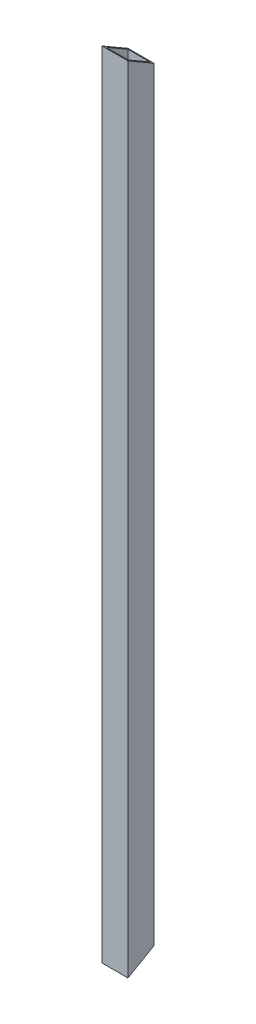
from build123d import *

# Parameters (mm, degrees)
SKETCH1_W               = 13
SKETCH1_H               = 13
SKETCH1_W_2             = 11
SKETCH1_H_2             = 11
BOSS_EXTRUDE1_DEPTH     = 400
CUT_EXTRUDE1_DEPTH      = 1
CUT_EXTRUDE1_DEPTH_BACK = 14
CUT_EXTRUDE3_DEPTH      = 1
CUT_EXTRUDE3_DEPTH_BACK = 14


with BuildPart() as part:
    # Sketch1 → Boss-Extrude1 (new body)
    with BuildSketch(Plane(origin=(0, 0, 0), x_dir=(1, 0, 0), z_dir=(0, 1, 0))):
        Rectangle(SKETCH1_W, SKETCH1_H)
        Rectangle(SKETCH1_W_2, SKETCH1_H_2, mode=Mode.SUBTRACT)
    extrude(amount=BOSS_EXTRUDE1_DEPTH)

    # Sketch2 → Cut-Extrude1 (cut, two sides)
    with BuildSketch(Plane.ZY.offset(6.5)) as cut_extrude1_sk:
        Polygon((708.34637623, 805.211194246), (6.5, 400), (-6.5, 392.494446501), (-708.34637623, -12.716747746), (-1518.768764723, 1390.976004715), (-102.076012262, 2208.903946707), align=None)
    extrude(amount=CUT_EXTRUDE1_DEPTH, mode=Mode.SUBTRACT)
    extrude(cut_extrude1_sk.sketch, amount=-CUT_EXTRUDE1_DEPTH_BACK, mode=Mode.SUBTRACT)

    # Sketch3 → Cut-Extrude3 (cut, two sides)
    with BuildSketch(Plane.ZY.offset(6.5)) as cut_extrude3_sk:
        Polygon((708.34637623, -405.211194246), (6.5, 0), (-6.5, 7.505553499), (-708.34637623, 412.716747746), (-1518.768764723, -990.976004715), (-102.076012262, -1808.903946707), align=None)
    extrude(amount=CUT_EXTRUDE3_DEPTH, mode=Mode.SUBTRACT)
    extrude(cut_extrude3_sk.sketch, amount=-CUT_EXTRUDE3_DEPTH_BACK, mode=Mode.SUBTRACT)


solid = part.part
